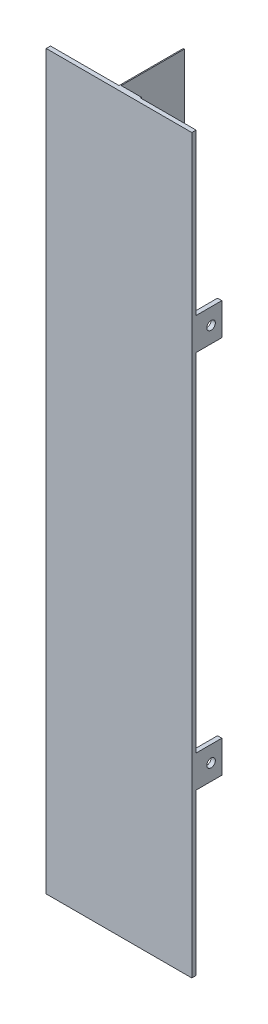
from build123d import *

# Parameters (mm, degrees)
DODANIE_WYCI_GNI_CIE1_DEPTH = 342
SZKIC3_W                    = 2
SZKIC3_H                    = 15
DODANIE_WYCI_GNI_CIE2_DEPTH = 12
SZKIC4_R                    = 2
WYTNIJ_WYCI_GNI_CIE1_DEPTH  = 10
SZKIC5_R                    = 2
WYTNIJ_WYCI_GNI_CIE2_DEPTH  = 10


with BuildPart() as part:
    # Szkic1 → Dodanie-wyciągnięcie1 (new body)
    with BuildSketch(Plane(origin=(0, 0, 0), x_dir=(1, 0, 0), z_dir=(0, 1, 0))):
        Polygon((0, 0), (0, 2), (32, 2), (32, 32), (32.5, 32), (32.5, 2.5), (42, 2.5), (42, 2), (68, 2), (68, 0), align=None)
    extrude(amount=DODANIE_WYCI_GNI_CIE1_DEPTH)

    # Szkic3 → Dodanie-wyciągnięcie2 (add)
    with BuildSketch(Plane(origin=(0, 0, -2), x_dir=(-1, 0, 0), z_dir=(0, 0, -1))):
        with Locations((-67, 82.5)):
            Rectangle(SZKIC3_W, SZKIC3_H)
        with Locations((-67, 259.5)):
            Rectangle(SZKIC3_W, SZKIC3_H)
        with Locations((-1, 82.5)):
            Rectangle(SZKIC3_W, SZKIC3_H)
        with Locations((-1, 259.5)):
            Rectangle(SZKIC3_W, SZKIC3_H)
    extrude(amount=DODANIE_WYCI_GNI_CIE2_DEPTH)

    # Szkic4 → Wytnij-wyciągnięcie1 (cut)
    with BuildSketch(Plane.ZY):
        with Locations((-9, 82.5)):
            Circle(SZKIC4_R)
        with Locations((-9, 259.5)):
            Circle(SZKIC4_R)
    extrude(amount=-WYTNIJ_WYCI_GNI_CIE1_DEPTH, mode=Mode.SUBTRACT)

    # Szkic5 → Wytnij-wyciągnięcie2 (cut)
    with BuildSketch(Plane(origin=(68, 0, 0), x_dir=(0, 0, -1), z_dir=(1, 0, 0))):
        with Locations((9, 259.5)):
            Circle(SZKIC5_R)
        with Locations((9, 82.5)):
            Circle(SZKIC5_R)
    extrude(amount=-WYTNIJ_WYCI_GNI_CIE2_DEPTH, mode=Mode.SUBTRACT)


solid = part.part
